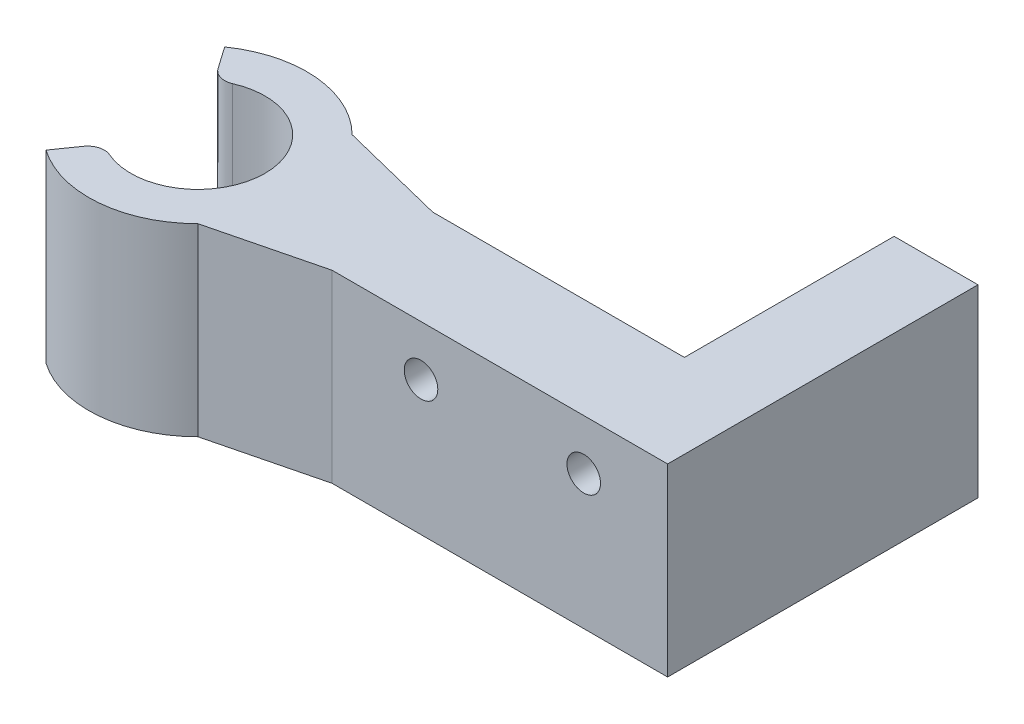
from build123d import *

# Parameters (mm, degrees)
ESQUISSE1_W             = 20
ESQUISSE1_H             = 6
BOSS_EXTRU_1_DEPTH      = 11
ESQUISSE2_R             = 1
ENL_V_MAT_EXTRU_1_DEPTH = 4
ESQUISSE3_W             = 5
ESQUISSE3_H             = 11
BOSS_EXTRU_2_DEPTH      = 12.5


with BuildPart() as part:
    # Esquisse1 → Boss.-Extru.1 (new body)
    with BuildSketch(Plane(origin=(0, 0, 0), x_dir=(1, 0, 0), z_dir=(0, 1, 0))):
        with Locations((21, 0)):
            Rectangle(ESQUISSE1_W, ESQUISSE1_H)
        with BuildLine():
            Line((11, -3), (11, 3))
            Line((11, 3), (4.596194078, 4.596194078))
            ThreePointArc((4.596194078, 4.596194078), (0.566512328, 6.475265538), (-3.728246836, 5.324488288))
            Line((-3.728246836, 5.324488288), (-2.809939195, 4.013009061))
            ThreePointArc((-2.809939195, 4.013009061), (-2.262538006, 3.624217858), (-1.592629721, 3.669268398))
            ThreePointArc((-1.592629721, 3.669268398), (4, 0), (-1.592629721, -3.669268398))
            ThreePointArc((-1.592629721, -3.669268398), (-2.262538006, -3.624217858), (-2.809939195, -4.013009061))
            Line((-2.809939195, -4.013009061), (-3.728246836, -5.324488288))
            ThreePointArc((-3.728246836, -5.324488288), (0.566512328, -6.475265538), (4.596194078, -4.596194078))
            Line((4.596194078, -4.596194078), (11, -3))
        make_face()
    extrude(amount=BOSS_EXTRU_1_DEPTH)

    # Esquisse2 → Enlèv. mat.-Extru.1 (cut)
    with BuildSketch(Plane.XY.offset(3)):
        with Locations((16.3, 8)):
            Circle(ESQUISSE2_R)
        with Locations((26, 8)):
            Circle(ESQUISSE2_R)
    extrude(amount=-ENL_V_MAT_EXTRU_1_DEPTH, mode=Mode.SUBTRACT)

    # Esquisse3 → Boss.-Extru.2 (add)
    with BuildSketch(Plane(origin=(0, 0, -3), x_dir=(-1, 0, 0), z_dir=(0, 0, -1))):
        with Locations((-28.5, 5.5)):
            Rectangle(ESQUISSE3_W, ESQUISSE3_H)
    extrude(amount=BOSS_EXTRU_2_DEPTH)


solid = part.part
